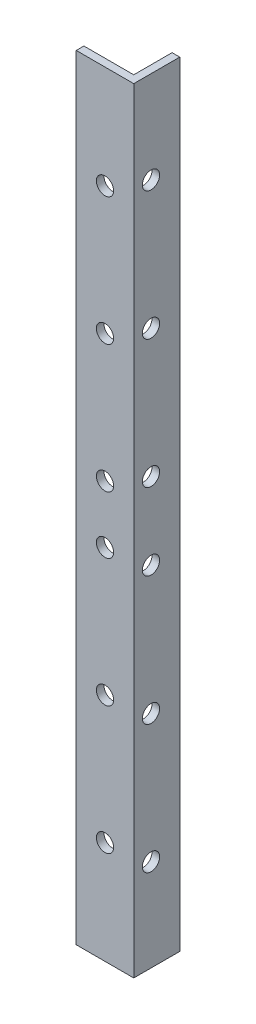
from build123d import *

# Parameters (mm, degrees)
BOSS_EXTRUDE1_DEPTH = 202
CUT_EXTRUDE1_REACH  = 14
SKETCH2_R           = 2.25
CUT_EXTRUDE2_REACH  = 17
SKETCH3_R           = 2.25


with BuildPart() as part:
    # Sketch1 → Boss-Extrude1 (new body)
    with BuildSketch(Plane(origin=(0, 0, 0), x_dir=(1, 0, 0), z_dir=(0, 1, 0))):
        Polygon((0, 0), (15, 0), (15, 12), (13, 12), (13, 2), (0, 2), align=None)
    extrude(amount=BOSS_EXTRUDE1_DEPTH)

    # Sketch2 → Cut-Extrude1 (cut, up to next)
    with BuildSketch(Plane.XY, mode=Mode.PRIVATE) as cut_extrude1_sk1:
        with Locations((7.5, 175.166666667)):
            Circle(SKETCH2_R)
    cut_extrude1_tool1 = extrude(cut_extrude1_sk1.sketch, amount=-CUT_EXTRUDE1_REACH, mode=Mode.PRIVATE) & part.part
    add(cut_extrude1_tool1.solids().sort_by_distance((7.5, 175.166667, 0))[0], mode=Mode.SUBTRACT)
    # Sketch2 → Cut-Extrude1 (cut, up to next)
    with BuildSketch(Plane.XY, mode=Mode.PRIVATE) as cut_extrude1_sk2:
        with Locations((7.5, 141.833333333)):
            Circle(SKETCH2_R)
    cut_extrude1_tool2 = extrude(cut_extrude1_sk2.sketch, amount=-CUT_EXTRUDE1_REACH, mode=Mode.PRIVATE) & part.part
    add(cut_extrude1_tool2.solids().sort_by_distance((7.5, 141.833333, 0))[0], mode=Mode.SUBTRACT)
    # Sketch2 → Cut-Extrude1 (cut, up to next)
    with BuildSketch(Plane.XY, mode=Mode.PRIVATE) as cut_extrude1_sk3:
        with Locations((7.5, 108.5)):
            Circle(SKETCH2_R)
    cut_extrude1_tool3 = extrude(cut_extrude1_sk3.sketch, amount=-CUT_EXTRUDE1_REACH, mode=Mode.PRIVATE) & part.part
    add(cut_extrude1_tool3.solids().sort_by_distance((7.5, 108.5, 0))[0], mode=Mode.SUBTRACT)
    # Sketch2 → Cut-Extrude1 (cut, up to next)
    with BuildSketch(Plane.XY, mode=Mode.PRIVATE) as cut_extrude1_sk4:
        with Locations((7.5, 93.5)):
            Circle(SKETCH2_R)
    cut_extrude1_tool4 = extrude(cut_extrude1_sk4.sketch, amount=-CUT_EXTRUDE1_REACH, mode=Mode.PRIVATE) & part.part
    add(cut_extrude1_tool4.solids().sort_by_distance((7.5, 93.5, 0))[0], mode=Mode.SUBTRACT)
    # Sketch2 → Cut-Extrude1 (cut, up to next)
    with BuildSketch(Plane.XY, mode=Mode.PRIVATE) as cut_extrude1_sk5:
        with Locations((7.5, 60.166666667)):
            Circle(SKETCH2_R)
    cut_extrude1_tool5 = extrude(cut_extrude1_sk5.sketch, amount=-CUT_EXTRUDE1_REACH, mode=Mode.PRIVATE) & part.part
    add(cut_extrude1_tool5.solids().sort_by_distance((7.5, 60.166667, 0))[0], mode=Mode.SUBTRACT)
    # Sketch2 → Cut-Extrude1 (cut, up to next)
    with BuildSketch(Plane.XY, mode=Mode.PRIVATE) as cut_extrude1_sk6:
        with Locations((7.5, 26.833333333)):
            Circle(SKETCH2_R)
    cut_extrude1_tool6 = extrude(cut_extrude1_sk6.sketch, amount=-CUT_EXTRUDE1_REACH, mode=Mode.PRIVATE) & part.part
    add(cut_extrude1_tool6.solids().sort_by_distance((7.5, 26.833333, 0))[0], mode=Mode.SUBTRACT)

    # Sketch3 → Cut-Extrude2 (cut, up to next)
    with BuildSketch(Plane(origin=(15, 0, 0), x_dir=(0, 0, -1), z_dir=(1, 0, 0)), mode=Mode.PRIVATE) as cut_extrude2_sk1:
        with Locations((4.5, 24)):
            Circle(SKETCH3_R)
    cut_extrude2_tool1 = extrude(cut_extrude2_sk1.sketch, amount=-CUT_EXTRUDE2_REACH, mode=Mode.PRIVATE) & part.part
    add(cut_extrude2_tool1.solids().sort_by_distance((15, 24, -4.5))[0], mode=Mode.SUBTRACT)
    # Sketch3 → Cut-Extrude2 (cut, up to next)
    with BuildSketch(Plane(origin=(15, 0, 0), x_dir=(0, 0, -1), z_dir=(1, 0, 0)), mode=Mode.PRIVATE) as cut_extrude2_sk2:
        with Locations((4.5, 57.5)):
            Circle(SKETCH3_R)
    cut_extrude2_tool2 = extrude(cut_extrude2_sk2.sketch, amount=-CUT_EXTRUDE2_REACH, mode=Mode.PRIVATE) & part.part
    add(cut_extrude2_tool2.solids().sort_by_distance((15, 57.5, -4.5))[0], mode=Mode.SUBTRACT)
    # Sketch3 → Cut-Extrude2 (cut, up to next)
    with BuildSketch(Plane(origin=(15, 0, 0), x_dir=(0, 0, -1), z_dir=(1, 0, 0)), mode=Mode.PRIVATE) as cut_extrude2_sk3:
        with Locations((4.5, 91)):
            Circle(SKETCH3_R)
    cut_extrude2_tool3 = extrude(cut_extrude2_sk3.sketch, amount=-CUT_EXTRUDE2_REACH, mode=Mode.PRIVATE) & part.part
    add(cut_extrude2_tool3.solids().sort_by_distance((15, 91, -4.5))[0], mode=Mode.SUBTRACT)
    # Sketch3 → Cut-Extrude2 (cut, up to next)
    with BuildSketch(Plane(origin=(15, 0, 0), x_dir=(0, 0, -1), z_dir=(1, 0, 0)), mode=Mode.PRIVATE) as cut_extrude2_sk4:
        with Locations((4.5, 111)):
            Circle(SKETCH3_R)
    cut_extrude2_tool4 = extrude(cut_extrude2_sk4.sketch, amount=-CUT_EXTRUDE2_REACH, mode=Mode.PRIVATE) & part.part
    add(cut_extrude2_tool4.solids().sort_by_distance((15, 111, -4.5))[0], mode=Mode.SUBTRACT)
    # Sketch3 → Cut-Extrude2 (cut, up to next)
    with BuildSketch(Plane(origin=(15, 0, 0), x_dir=(0, 0, -1), z_dir=(1, 0, 0)), mode=Mode.PRIVATE) as cut_extrude2_sk5:
        with Locations((4.5, 144.5)):
            Circle(SKETCH3_R)
    cut_extrude2_tool5 = extrude(cut_extrude2_sk5.sketch, amount=-CUT_EXTRUDE2_REACH, mode=Mode.PRIVATE) & part.part
    add(cut_extrude2_tool5.solids().sort_by_distance((15, 144.5, -4.5))[0], mode=Mode.SUBTRACT)
    # Sketch3 → Cut-Extrude2 (cut, up to next)
    with BuildSketch(Plane(origin=(15, 0, 0), x_dir=(0, 0, -1), z_dir=(1, 0, 0)), mode=Mode.PRIVATE) as cut_extrude2_sk6:
        with Locations((4.5, 178)):
            Circle(SKETCH3_R)
    cut_extrude2_tool6 = extrude(cut_extrude2_sk6.sketch, amount=-CUT_EXTRUDE2_REACH, mode=Mode.PRIVATE) & part.part
    add(cut_extrude2_tool6.solids().sort_by_distance((15, 178, -4.5))[0], mode=Mode.SUBTRACT)


solid = part.part
